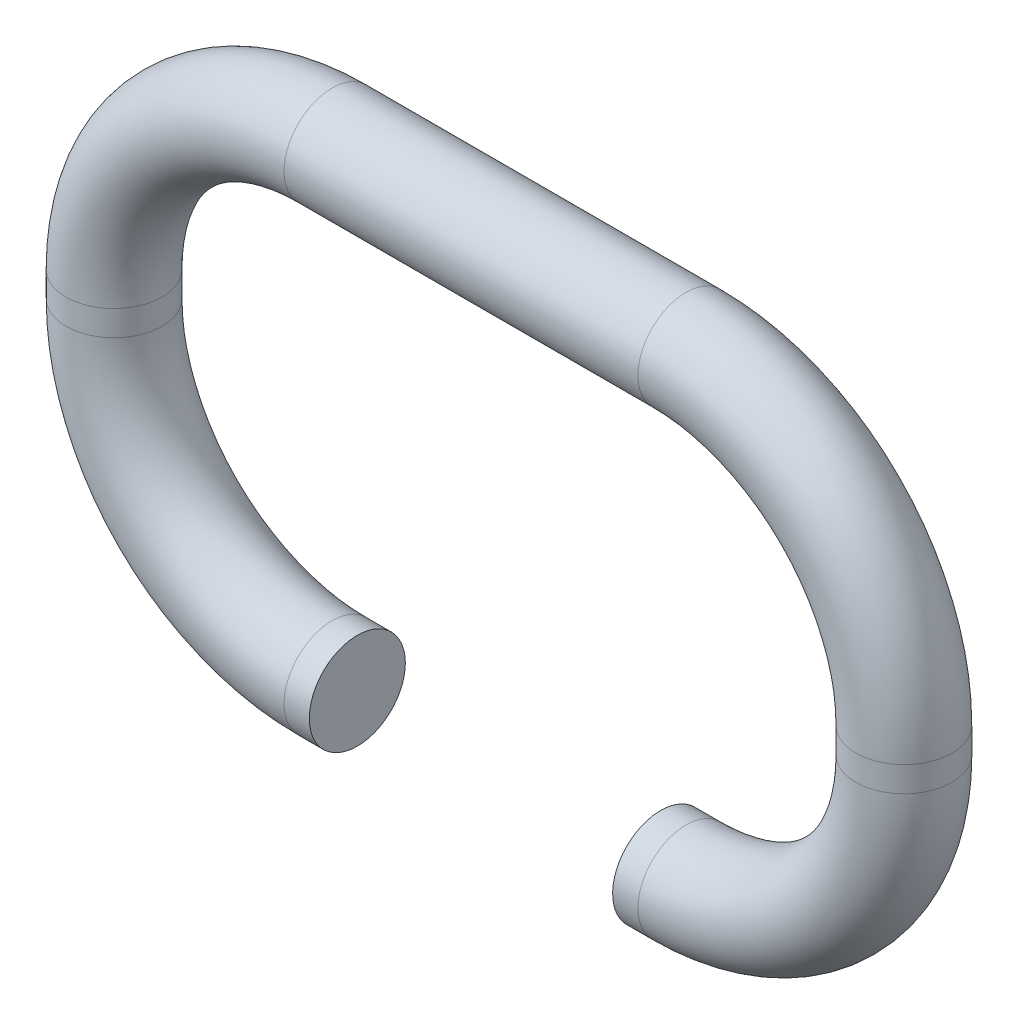
from build123d import *

# Parameters (mm, degrees)
ESQUISSE25_R = 1.9


with BuildPart() as part:
    # Balayage7: sweep along a path in Esquisse23
    with BuildLine(Plane.XY) as balayage7_path:
        Line((2, -5), (1, -5))
        ThreePointArc((1, -5), (0.292893219, -4.707106781), (0, -4))
        Line((0, -4), (0, -3))
        ThreePointArc((0, -3), (0.292893219, -2.292893219), (1, -2))
        Line((1, -2), (15, -2))
        ThreePointArc((15, -2), (15.707106781, -2.292893219), (16, -3))
        Line((16, -3), (16, -4))
        ThreePointArc((16, -4), (15.707106781, -4.707106781), (15, -5))
        Line((15, -5), (14, -5))
    # Esquisse25 → Balayage7 (sweep)
    with BuildSketch(Plane(origin=(2, 0, 0), x_dir=(0, 0, -1), z_dir=(1, 0, 0))):
        with Locations((0, -12.623519933)):
            Circle(ESQUISSE25_R)
    sweep(path=balayage7_path.line)


solid = part.part
